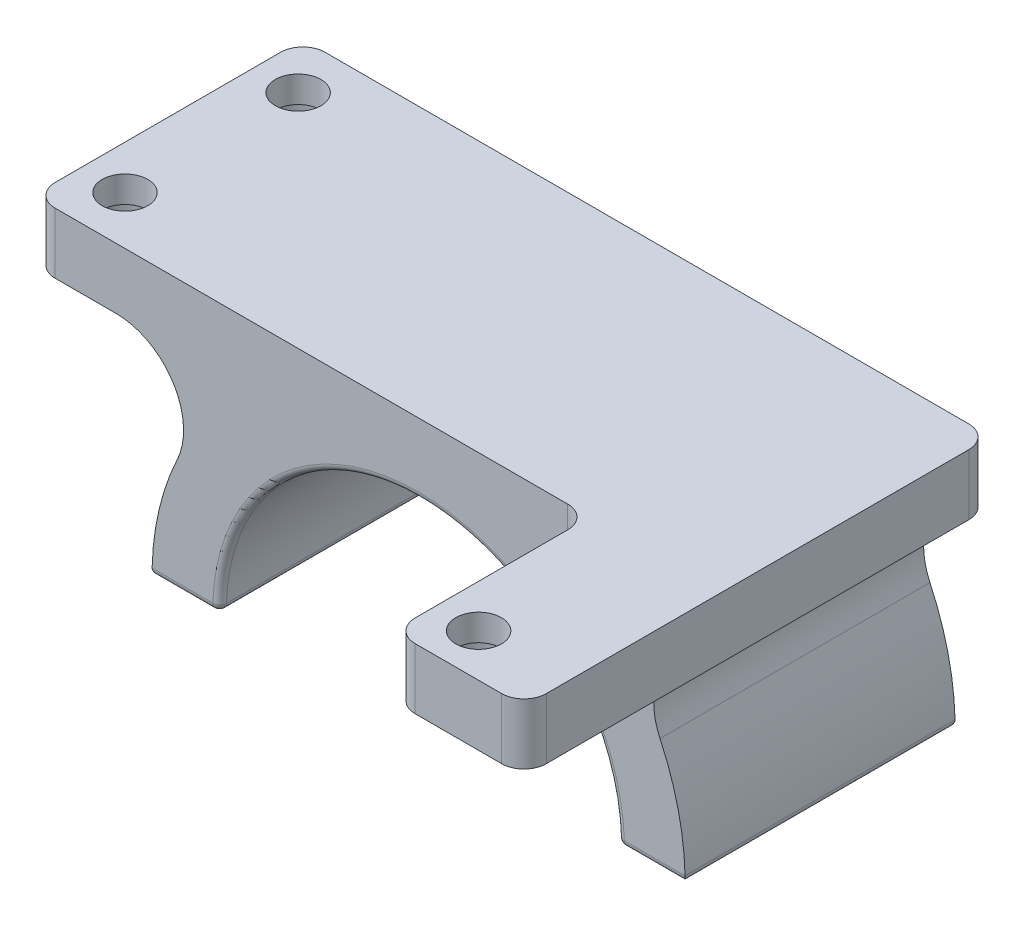
from build123d import *

# Parameters (mm, degrees)
SKETCH1_R           = 39.5
BOSS_EXTRUDE1_DEPTH = 40
CUT_EXTRUDE2_DEPTH  = 41
CUT_EXTRUDE3_DEPTH  = 41
FILLET2_R           = 1
SKETCH6_W           = 114.3
SKETCH6_H           = 9
BOSS_EXTRUDE2_DEPTH = 40
FILLET6_R           = 10
CUT_EXTRUDE4_REACH  = 42
SKETCH9_R           = 3.3782
SKETCH11_W          = 31.75
SKETCH11_H          = 9
BOSS_EXTRUDE3_DEPTH = 29.21
SKETCH4_W           = 3.002871012
SKETCH4_H           = 30
FILLET7_R           = 3.302
SKETCH13_R          = 5.08
CUT_EXTRUDE6_DEPTH  = 5.08
SKETCH15_R          = 3.3782
CUT_EXTRUDE8_DEPTH  = 10
SKETCH16_R          = 5.08
CUT_EXTRUDE9_DEPTH  = 5.08
SKETCH17_W          = 36.586278343
SKETCH17_H          = 70.835632368
CUT_EXTRUDE10_DEPTH = 10
FILLET8_R           = 3.302


with BuildPart() as part:
    # Sketch1 → Boss-Extrude1 (new body)
    with BuildSketch(Plane.XY):
        Circle(SKETCH1_R)
    extrude(amount=BOSS_EXTRUDE1_DEPTH)

    # Sketch2 → Cut-Extrude2 (cut, through all)
    with BuildSketch(Plane(origin=(0, 0, 0), x_dir=(-1, 0, 0), z_dir=(0, 0, -1))):
        with BuildLine():
            Line((-39.5, 0), (39.5, 0))
            ThreePointArc((39.5, 0), (0, -39.5), (-39.5, 0))
        make_face()
    extrude(amount=-CUT_EXTRUDE2_DEPTH, mode=Mode.SUBTRACT)

    # Sketch3 → Cut-Extrude3 (cut, through all)
    with BuildSketch(Plane(origin=(0, 0, 0), x_dir=(-1, 0, 0), z_dir=(0, 0, -1))):
        with BuildLine():
            Line((-29.5, 0), (29.5, 0))
            ThreePointArc((29.5, 0), (0, 29.5), (-29.5, 0))
        make_face()
    extrude(amount=-CUT_EXTRUDE3_DEPTH, mode=Mode.SUBTRACT)

    # Fillet2
    fillet2_edges = [part.edges().sort_by_distance(p)[0] for p in [
        (-34.5, 0, 0),
        (-34.5, 0, 40),
        (0, 29.5, 40),
        (29.5, 0, 20),
        (-29.5, 0, 20),
        (0, 29.5, 0),
        (-39.5, 0, 20),
        (34.5, 0, 0),
        (39.5, 0, 20),
        (34.5, 0, 40),
    ]]
    fillet(fillet2_edges, radius=FILLET2_R)

    # Sketch6 → Boss-Extrude2 (add)
    with BuildSketch(Plane(origin=(0, 0, 0), x_dir=(-1, 0, 0), z_dir=(0, 0, -1))):
        with Locations((0, 35.5)):
            Rectangle(SKETCH6_W, SKETCH6_H)
    extrude(amount=-BOSS_EXTRUDE2_DEPTH)

    # Fillet6
    fillet6_edges = [part.edges().sort_by_distance(p)[0] for p in [
        (-24.47958333, 31, 20),
        (24.47958333, 31, 20),
    ]]
    fillet(fillet6_edges, radius=FILLET6_R)

    # Sketch9 → Cut-Extrude4 (cut, up to next)
    with BuildSketch(Plane(origin=(0, 40, 0), x_dir=(1, 0, 0), z_dir=(0, 1, 0)), mode=Mode.PRIVATE) as cut_extrude4_sk1:
        with Locations((-50.677371465, -7.173)):
            Circle(SKETCH9_R)
    cut_extrude4_tool1 = extrude(cut_extrude4_sk1.sketch, amount=-CUT_EXTRUDE4_REACH, mode=Mode.PRIVATE) & part.part
    add(cut_extrude4_tool1.solids().sort_by_distance((-50.677371, 40, 7.173))[0], mode=Mode.SUBTRACT)
    # Sketch9 → Cut-Extrude4 (cut, up to next)
    with BuildSketch(Plane(origin=(0, 40, 0), x_dir=(1, 0, 0), z_dir=(0, 1, 0)), mode=Mode.PRIVATE) as cut_extrude4_sk2:
        with Locations((-50.677371465, -32.827)):
            Circle(SKETCH9_R)
    cut_extrude4_tool2 = extrude(cut_extrude4_sk2.sketch, amount=-CUT_EXTRUDE4_REACH, mode=Mode.PRIVATE) & part.part
    add(cut_extrude4_tool2.solids().sort_by_distance((-50.677371, 40, 32.827))[0], mode=Mode.SUBTRACT)

    # Sketch11 → Boss-Extrude3 (add)
    with BuildSketch(Plane.XY.offset(40)):
        with Locations((41.275, 35.5)):
            Rectangle(SKETCH11_W, SKETCH11_H)
    extrude(amount=BOSS_EXTRUDE3_DEPTH)

    # Sketch4 → Cut-Revolve1 (revolve, cut)
    with BuildSketch(Plane.XZ):
        with Locations((34.48557529, 20)):
            Rectangle(SKETCH4_W, SKETCH4_H)
    revolve(axis=Axis((0, 0, 0), (0, 0, 1)), mode=Mode.SUBTRACT)

    # Fillet7
    fillet7_edges = [part.edges().sort_by_distance(p)[0] for p in [
        (25.4, 35.5, 40),
        (25.4, 35.5, 69.21),
        (57.15, 35.5, 69.21),
        (-57.15, 35.5, 0),
        (57.15, 35.5, 0),
        (-57.15, 35.5, 40),
    ]]
    fillet(fillet7_edges, radius=FILLET7_R)

    # Sketch13 → Cut-Extrude6 (cut)
    with BuildSketch(Plane.XZ.offset(-31)):
        with Locations((-50.677371465, 32.827)):
            Circle(SKETCH13_R)
        with Locations((-50.677371465, 7.173)):
            Circle(SKETCH13_R)
    extrude(amount=-CUT_EXTRUDE6_DEPTH, mode=Mode.SUBTRACT)

    # Sketch15 → Cut-Extrude8 (cut, through all)
    with BuildSketch(Plane.XZ.offset(-31)):
        with Locations((31.75, 62.86)):
            Circle(SKETCH15_R)
    extrude(amount=-CUT_EXTRUDE8_DEPTH, mode=Mode.SUBTRACT)

    # Sketch16 → Cut-Extrude9 (cut)
    with BuildSketch(Plane.XZ.offset(-31)):
        with Locations((31.75, 62.86)):
            Circle(SKETCH16_R)
    extrude(amount=-CUT_EXTRUDE9_DEPTH, mode=Mode.SUBTRACT)

    # Sketch17 → Cut-Extrude10 (cut, through all)
    with BuildSketch(Plane.XZ.offset(-31)):
        with Locations((63.117797564, 35.417816184)):
            Rectangle(SKETCH17_W, SKETCH17_H)
    extrude(amount=-CUT_EXTRUDE10_DEPTH, mode=Mode.SUBTRACT)

    # Fillet8
    fillet8_edges = [part.edges().sort_by_distance(p)[0] for p in [
        (44.824658392, 35.5, 69.21),
        (44.824658392, 35.5, 0),
    ]]
    fillet(fillet8_edges, radius=FILLET8_R)


solid = part.part
